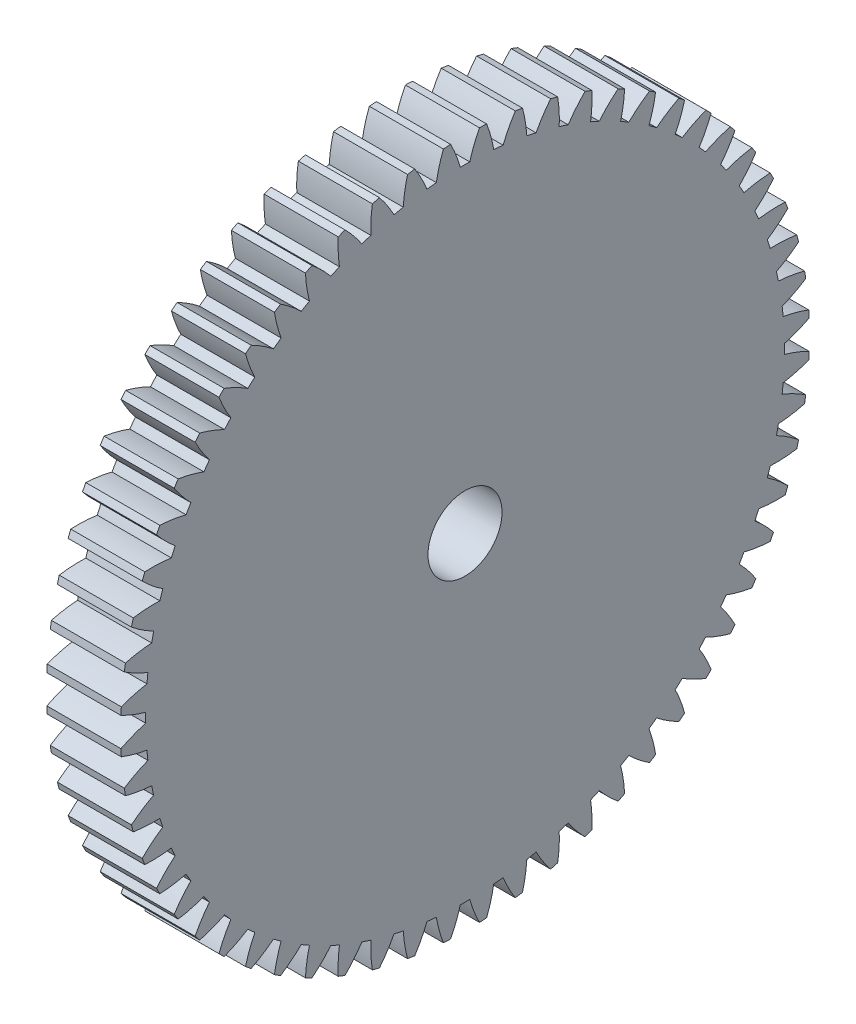
from build123d import *

# Parameters (mm, degrees)
BASPROSKE_W     = 10
BASPROSKE_H     = 46.5
TOOTHCUT_DEPTH  = 67.516915142
TEETHCUTS_COUNT = 60
TEETHCUTS_ANGLE = 354
BORSKE_R        = 5
BORE_DEPTH      = 50.0000508


with BuildPart() as part:
    # BasProSke → Base-Revolve (revolve)
    with BuildSketch(Plane(origin=(0, 0, 0), x_dir=(1, 0, 0), z_dir=(0, 1, 0)), mode=Mode.PRIVATE) as base_revolve_sk:
        with Locations((5, 23.25)):
            Rectangle(BASPROSKE_W, BASPROSKE_H)
    revolve(base_revolve_sk.sketch.rotate(Axis((-10, 0, 0), (1, 0, 0)), 180), axis=Axis((-10, 0, 0), (1, 0, 0)))

    # TooCutSke → ToothCut (cut, through all)
    with BuildSketch(Plane(origin=(0, 0, 0), x_dir=(0, 0, -1), z_dir=(1, 0, 0))):
        with BuildLine():
            ThreePointArc((0.638657789, 43.119270544), (0, 43.124), (-0.638657789, 43.119270544))
            ThreePointArc((-0.638657789, 43.119270544), (-1.21237986, 44.83490593), (-1.955410142, 46.484289995))
            ThreePointArc((-1.955410142, 46.484289995), (0, 46.5254), (1.955410142, 46.484289995))
            ThreePointArc((1.955410142, 46.484289995), (1.21237986, 44.83490593), (0.638657789, 43.119270544))
        make_face()
    toothcut = extrude(amount=TOOTHCUT_DEPTH, mode=Mode.SUBTRACT)

    # TeethCuts: ToothCut ×60 about axis
    teethcuts_axis = Axis((-10, 0, 0), (1, 0, 0))
    for i in range(1, TEETHCUTS_COUNT):
        add(toothcut.rotate(teethcuts_axis, i * TEETHCUTS_ANGLE / (TEETHCUTS_COUNT - 1)), mode=Mode.SUBTRACT)

    # BorSke → Bore (cut, symmetric)
    with BuildSketch(Plane(origin=(0, 0, 0), x_dir=(0, 0, -1), z_dir=(1, 0, 0))):
        with Locations(Location((0, 0, 0), (0, 0, 180))):
            Circle(BORSKE_R)
    extrude(amount=BORE_DEPTH, both=True, mode=Mode.SUBTRACT)


solid = part.part
